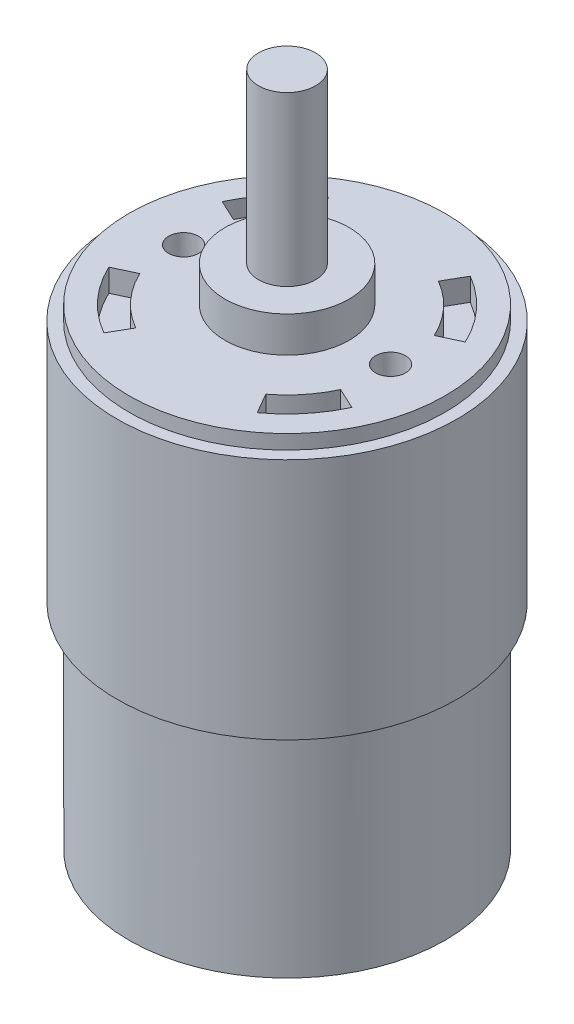
from build123d import *

# Parameters (mm, degrees)
SKETCH2_R            = 22.1488
BOSS_EXTRUDE4_DEPTH  = 66.0908
SKETCH4_R            = 8.6995
BOSS_EXTRUDE5_DEPTH  = 5.0038
SKETCH9_R            = 4.0005
BOSS_EXTRUDE6_DEPTH  = 23.5458
SKETCH10_R           = 8.7503
BOSS_EXTRUDE7_DEPTH  = 6.7056
SKETCH11_R           = 2.5019
BOSS_EXTRUDE8_DEPTH  = 2.413
SKETCH12_R           = 23.8125
BOSS_EXTRUDE9_DEPTH  = 34.0106
SKETCH13_R           = 2.0955
CUT_EXTRUDE1_DEPTH   = 3.175
CUT_EXTRUDE2_DEPTH   = 3.175
SKETCH15_R           = 20.958175
SKETCH15_R_2         = 8.7503
CUT_EXTRUDE3_DEPTH   = 3.175
SKETCH16_R           = 7.1628
SKETCH16_R_2         = 2.5019
CUT_EXTRUDE4_DEPTH   = 2.54
BOSS_EXTRUDE12_DEPTH = 3.175
BOSS_EXTRUDE13_DEPTH = 3.175
SKETCH20_R           = 1.5875
CUT_EXTRUDE5_DEPTH   = 3.175


with BuildPart() as part:
    # Sketch2 → Boss-Extrude4 (new body)
    with BuildSketch(Plane(origin=(0, 0, 0), x_dir=(1, 0, 0), z_dir=(0, 1, 0))):
        Circle(SKETCH2_R)
    extrude(amount=BOSS_EXTRUDE4_DEPTH)

    # Sketch4 → Boss-Extrude5 (add)
    with BuildSketch(Plane(origin=(0, 66.0908, 0), x_dir=(1, 0, 0), z_dir=(0, 1, 0))):
        Circle(SKETCH4_R)
    extrude(amount=BOSS_EXTRUDE5_DEPTH)

    # Sketch9 → Boss-Extrude6 (add)
    with BuildSketch(Plane(origin=(0, 71.0946, 0), x_dir=(1, 0, 0), z_dir=(0, 1, 0))):
        Circle(SKETCH9_R)
    extrude(amount=BOSS_EXTRUDE6_DEPTH)

    # Sketch10 → Boss-Extrude7 (add)
    with BuildSketch(Plane.XZ):
        Circle(SKETCH10_R)
    extrude(amount=BOSS_EXTRUDE7_DEPTH)

    # Sketch11 → Boss-Extrude8 (add)
    with BuildSketch(Plane.XZ.offset(6.7056)):
        Circle(SKETCH11_R)
    extrude(amount=BOSS_EXTRUDE8_DEPTH)

    # Sketch12 → Boss-Extrude9 (add)
    with BuildSketch(Plane(origin=(0, 64.0842, 0), x_dir=(-1, 0, 0), z_dir=(0, -1, 0))):
        Circle(SKETCH12_R)
    extrude(amount=BOSS_EXTRUDE9_DEPTH)

    # Sketch13 → Cut-Extrude1 (cut)
    with BuildSketch(Plane(origin=(0, 66.0908, 0), x_dir=(1, 0, 0), z_dir=(0, 1, 0))):
        with Locations((-14.5034, 0)):
            Circle(SKETCH13_R)
        with Locations((14.5034, 0)):
            Circle(SKETCH13_R)
    extrude(amount=-CUT_EXTRUDE1_DEPTH, mode=Mode.SUBTRACT)

    # Sketch14 → Cut-Extrude2 (cut)
    with BuildSketch(Plane(origin=(0, 66.0908, 0), x_dir=(1, 0, 0), z_dir=(0, 1, 0))):
        with BuildLine():
            Line((-14.070005184, -6.560951168), (-17.033311719, -7.942763698))
            ThreePointArc((-17.033311719, -7.942763698), (-13.856523006, -12.697163994), (-9.397090019, -16.276237356))
            Line((-9.397090019, -16.276237356), (-7.76226652, -13.444639995))
            ThreePointArc((-7.76226652, -13.444639995), (-11.445886375, -10.4882225), (-14.070005184, -6.560951168))
        make_face()
        with BuildLine():
            ThreePointArc((-10.080336815, 15.862156631), (-14.123267338, 12.399779151), (-17.033311719, 7.942763698))
            Line((-17.033311719, 7.942763698), (-14.070005184, 6.560951168))
            ThreePointArc((-14.070005184, 6.560951168), (-11.711998853, 10.190201616), (-8.44372295, 13.027458265))
            Line((-8.44372295, 13.027458265), (-10.080336815, 15.862156631))
        make_face()
        with BuildLine():
            ThreePointArc((17.033311719, 7.942763698), (13.856523006, 12.697163994), (9.397090019, 16.276237356))
            Line((9.397090019, 16.276237356), (7.76226652, 13.444639995))
            ThreePointArc((7.76226652, 13.444639995), (11.445886375, 10.4882225), (14.070005184, 6.560951168))
            Line((14.070005184, 6.560951168), (17.033311719, 7.942763698))
        make_face()
        with BuildLine():
            Line((9.385927189, -12.365900571), (11.031460095, -15.21604717))
            ThreePointArc((11.031460095, -15.21604717), (14.495965555, -11.961947414), (17.033311719, -7.942763698))
            Line((17.033311719, -7.942763698), (14.070005184, -6.560951168))
            ThreePointArc((14.070005184, -6.560951168), (12.081785889, -9.748926908), (9.385927189, -12.365900571))
        make_face()
    extrude(amount=-CUT_EXTRUDE2_DEPTH, mode=Mode.SUBTRACT)

    # Sketch15 → Cut-Extrude3 (cut)
    with BuildSketch(Plane.XZ):
        Circle(SKETCH15_R)
        Circle(SKETCH15_R_2, mode=Mode.SUBTRACT)
    extrude(amount=-CUT_EXTRUDE3_DEPTH, mode=Mode.SUBTRACT)

    # Sketch16 → Cut-Extrude4 (cut)
    with BuildSketch(Plane.XZ.offset(6.7056)):
        Circle(SKETCH16_R)
        Circle(SKETCH16_R_2, mode=Mode.SUBTRACT)
    extrude(amount=-CUT_EXTRUDE4_DEPTH, mode=Mode.SUBTRACT)

    # Sketch18 → Boss-Extrude12 (add)
    with BuildSketch(Plane.XZ):
        with BuildLine():
            ThreePointArc((20.865163654, 0), (20.780212376, 1.88091146), (20.52605029, 3.746506881))
            Line((20.52605029, 3.746506881), (17.399, 3.746506881))
            Line((17.399, 3.746506881), (17.399, -2.603493119))
            Line((17.399, -2.603493119), (20.702098393, -2.603493119))
            ThreePointArc((20.702098393, -2.603493119), (20.824357436, -1.304297387), (20.865163654, 0))
        make_face()
    extrude(amount=-BOSS_EXTRUDE12_DEPTH)

    # Sketch19 → Boss-Extrude13 (add)
    with BuildSketch(Plane(origin=(0, 0, 0), x_dir=(-1, 0, 0), z_dir=(0, -1, 0))):
        with BuildLine():
            Line((20.716285244, -3.175), (17.399, -3.175))
            Line((17.399, -3.175), (17.399, 3.175))
            Line((17.399, 3.175), (20.716285244, 3.175))
            ThreePointArc((20.716285244, 3.175), (20.958175, 0), (20.716285244, -3.175))
        make_face()
    extrude(amount=-BOSS_EXTRUDE13_DEPTH)

    # Sketch20 → Cut-Extrude5 (cut)
    with BuildSketch(Plane(origin=(0, 3.175, 0), x_dir=(-1, 0, 0), z_dir=(0, -1, 0))):
        with Locations((-15.1765, 6.730993119)):
            Circle(SKETCH20_R)
    extrude(amount=-CUT_EXTRUDE5_DEPTH, mode=Mode.SUBTRACT)


solid = part.part
